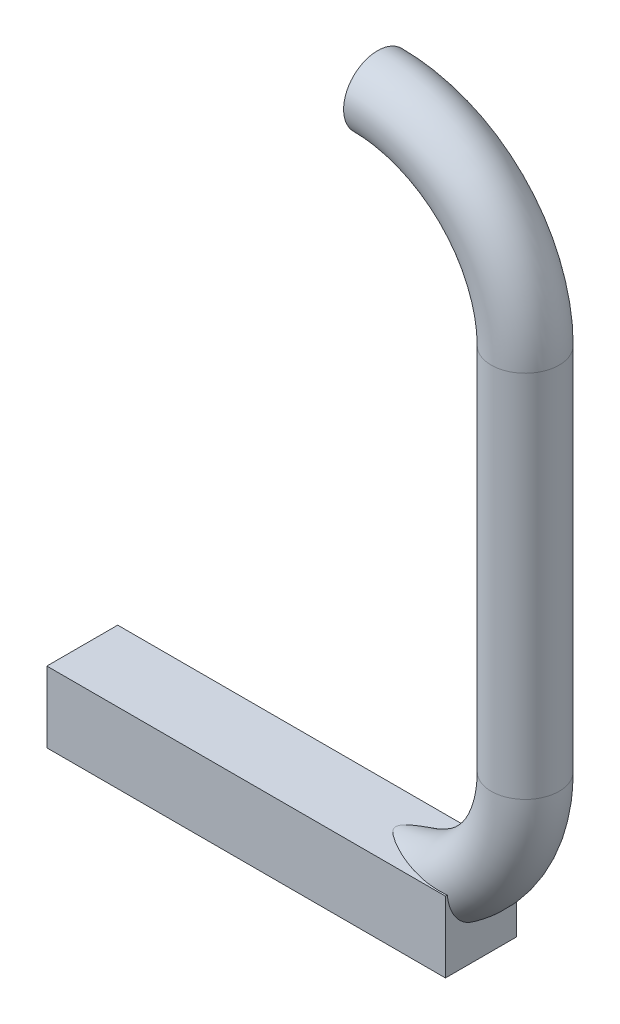
from build123d import *

# Parameters (mm, degrees)
VARREDURA1_PROFILE_R          = 2.3
ESBO_O18_W                    = 4.8
ESBO_O18_H                    = 4.8
RESSALTO_EXTRUS_O1_DEPTH      = 20
RESSALTO_EXTRUS_O1_DEPTH_BACK = 7


with BuildPart() as part:
    # Varredura1: sweep along a path in Esboço1
    with BuildLine(Plane.XY) as varredura1_path:
        ThreePointArc((-10, -10), (-2.928932188, -7.071067812), (0, 0))
        Line((0, 0), (0, 25))
        ThreePointArc((0, 25), (-2.928932188, 32.071067812), (-10, 35))
    # Varredura1 profile (on start of the path) → Varredura1 (sweep)
    with BuildSketch(Plane(origin=(-10, -10, 0), x_dir=(0, 1, 0), z_dir=(1, 0, 0))):
        Circle(VARREDURA1_PROFILE_R)
    sweep(path=varredura1_path.line)

    # Esboço18 → Ressalto-extrusão1 (add, two sides)
    with BuildSketch(Plane.ZY.offset(10)) as ressalto_extrus_o1_sk:
        with Locations((0, -10)):
            Rectangle(ESBO_O18_W, ESBO_O18_H)
    extrude(amount=RESSALTO_EXTRUS_O1_DEPTH)
    extrude(ressalto_extrus_o1_sk.sketch, amount=-RESSALTO_EXTRUS_O1_DEPTH_BACK)


solid = part.part
